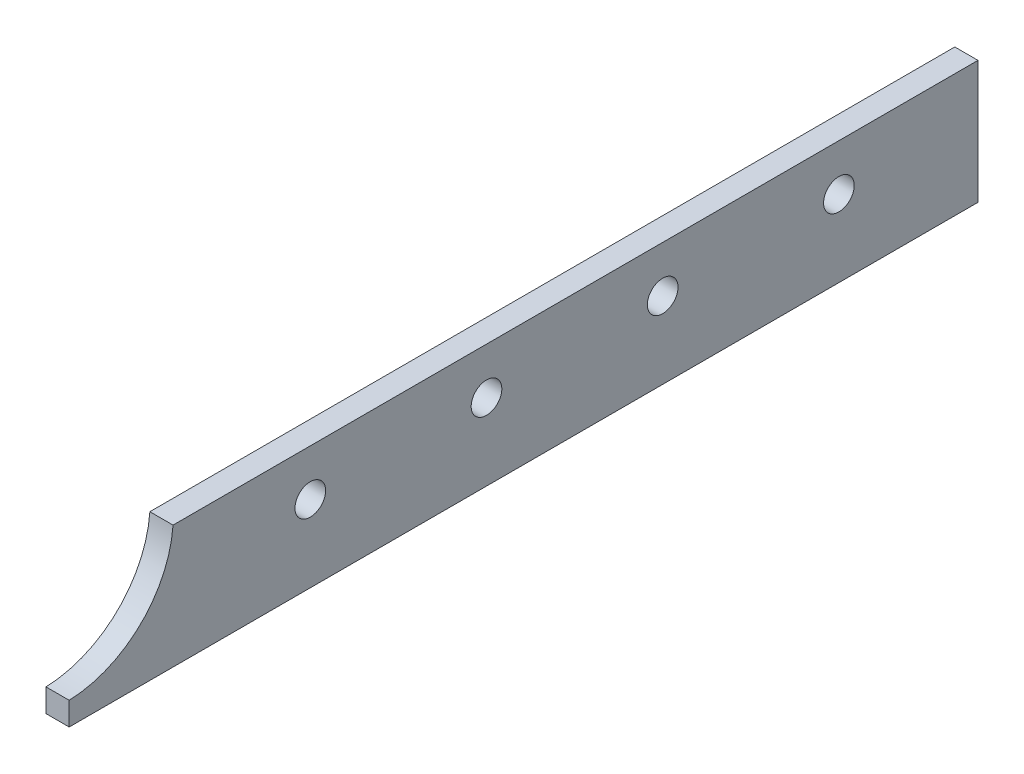
from build123d import *

# Parameters (mm, degrees)
BOSS_EXTRUDE1_DEPTH = 3.175
SKETCH3_R           = 2.1
CUT_EXTRUDE1_DEPTH  = 4.175


with BuildPart() as part:
    # Sketch1 → Boss-Extrude1 (new body)
    with BuildSketch(Plane(origin=(0, 0, 0), x_dir=(0, 0, -1), z_dir=(1, 0, 0))):
        with BuildLine():
            Line((-62.23, -8.4201), (62.23, -8.4201))
            Line((62.23, -8.4201), (62.23, 8.4201))
            Line((62.23, 8.4201), (-48.006, 8.4201))
            ThreePointArc((-48.006, 8.4201), (-52.493538794, -1.144281181), (-62.23, -5.2451))
            Line((-62.23, -5.2451), (-62.23, -8.4201))
        make_face()
    extrude(amount=BOSS_EXTRUDE1_DEPTH)

    # Sketch3 → Cut-Extrude1 (cut, through all)
    with BuildSketch(Plane.ZY):
        with Locations((-43.18, 2.0701)):
            Circle(SKETCH3_R)
        with Locations((-19.05, 2.0701)):
            Circle(SKETCH3_R)
        with Locations((5.08, 2.0701)):
            Circle(SKETCH3_R)
        with Locations((29.21, 2.0701)):
            Circle(SKETCH3_R)
    extrude(amount=-CUT_EXTRUDE1_DEPTH, mode=Mode.SUBTRACT)


solid = part.part
